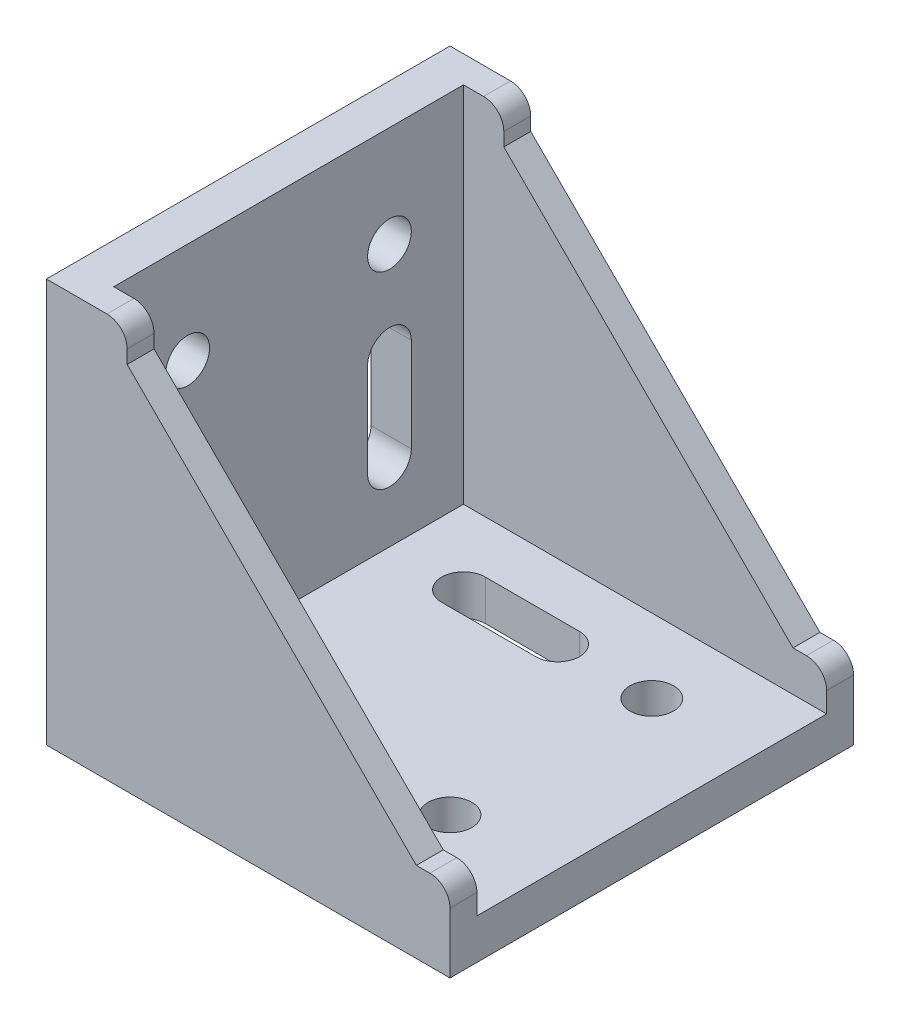
from build123d import *

# Parameters (mm, degrees)
EXTRUDE_1_DEPTH     = 30
EXTRUDE_2_DEPTH     = 4
SKETCH_3_R          = 3.25
CUT_EXTRUDE_1_DEPTH = 7
SKETCH_4_W          = 2.5
SKETCH_4_H          = 6
EXTRUDE_3_DEPTH     = 2.5


with BuildPart() as part:
    # Эскиз1 → Бобышка-Вытянуть1 (new body, symmetric)
    with BuildSketch(Plane.XY):
        Polygon((0, 60), (0, 0), (60, 0), (60, 6), (6, 6), (6, 60), align=None)
    extrude(amount=EXTRUDE_1_DEPTH, both=True)

    # Эскиз2 → Бобышка-Вытянуть2 (add)
    with BuildSketch(Plane.XY.offset(30)):
        with BuildLine():
            Line((60, 6), (6, 6))
            Line((6, 6), (6, 60))
            Line((6, 60), (9, 60))
            ThreePointArc((9, 60), (11.121320344, 59.121320344), (12, 57))
            Line((12, 57), (12, 55))
            Line((12, 55), (55, 12))
            Line((55, 12), (57, 12))
            ThreePointArc((57, 12), (59.121320344, 11.121320344), (60, 9))
            Line((60, 9), (60, 6))
        make_face()
    extrude_2 = extrude(amount=-EXTRUDE_2_DEPTH)

    # Зеркальное отражение2: Бобышка-Вытянуть2 across plane
    add(extrude_2.mirror(Plane.XY))

    # Эскиз3 → Вырез-Вытянуть1 (cut, through all)
    with BuildSketch(Plane(origin=(0, 6, 0), x_dir=(1, 0, 0), z_dir=(0, 1, 0))):
        with Locations(Location((45, -15, 0), (0, 0, 270))):  # turned: the seam where the file's is
            Circle(SKETCH_3_R)
        with Locations(Location((45, 15, 0), (0, 0, 90))):  # turned: the seam where the file's is
            Circle(SKETCH_3_R)
        with BuildLine():
            Line((17, -11.75), (31, -11.75))
            ThreePointArc((31, -11.75), (34.25, -15), (31, -18.25))
            Line((31, -18.25), (17, -18.25))
            ThreePointArc((17, -18.25), (13.75, -15), (17, -11.75))
        make_face()
        with BuildLine():
            Line((17, 11.75), (31, 11.75))
            ThreePointArc((31, 11.75), (34.25, 15), (31, 18.25))
            Line((31, 18.25), (17, 18.25))
            ThreePointArc((17, 18.25), (13.75, 15), (17, 11.75))
        make_face()
    cut_extrude_1 = extrude(amount=-CUT_EXTRUDE_1_DEPTH, mode=Mode.SUBTRACT)

    # Эскиз4 → Бобышка-Вытянуть3 (add)
    with BuildSketch(Plane.XZ):
        with Locations((4.25, -15)):
            Rectangle(SKETCH_4_W, SKETCH_4_H)
        with Locations((55.75, -15)):
            Rectangle(SKETCH_4_W, SKETCH_4_H)
        with Locations((55.75, 15)):
            Rectangle(SKETCH_4_W, SKETCH_4_H)
        with Locations((4.25, 15)):
            Rectangle(SKETCH_4_W, SKETCH_4_H)
    extrude_3 = extrude(amount=EXTRUDE_3_DEPTH)

    # Зеркальное отражение3: Вырез-Вытянуть1, Бобышка-Вытянуть3 across plane
    add(cut_extrude_1.mirror(Plane(origin=(0, 0, 0), x_dir=(0, 0, 1), z_dir=(-0.707106781, 0.707106781, 0))), mode=Mode.SUBTRACT)
    add(extrude_3.mirror(Plane(origin=(0, 0, 0), x_dir=(0, 0, 1), z_dir=(-0.707106781, 0.707106781, 0))))


solid = part.part
